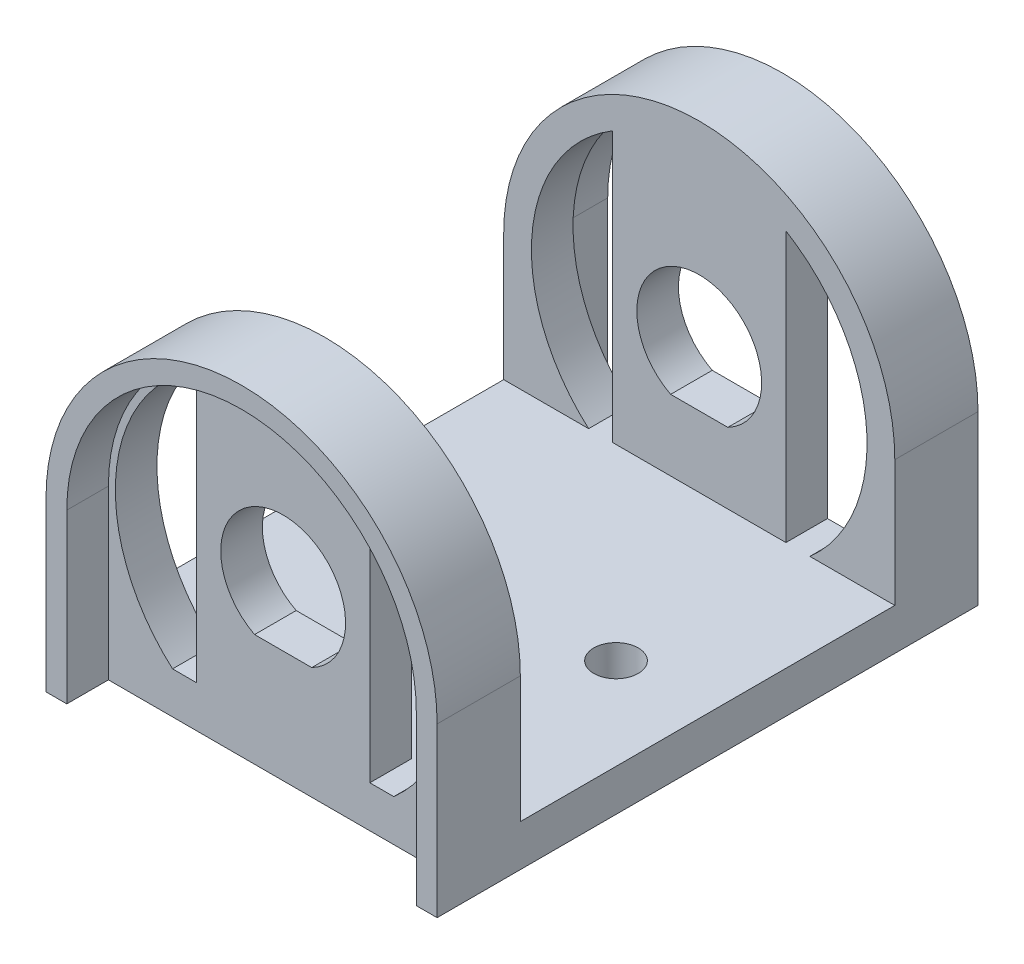
from build123d import *

# Parameters (mm, degrees)
BOSS_EXTRUDE2_DEPTH     = 19.5
SKETCH4_W               = 27
SKETCH4_H               = 23.2
CUT_EXTRUDE2_DEPTH      = 15.1
CUT_EXTRUDE2_DEPTH_BACK = 15.1
CUT_EXTRUDE4_DEPTH      = 3
SKETCH5_R               = 1.6
CUT_EXTRUDE5_DEPTH      = 14.1
CUT_EXTRUDE5_DEPTH_BACK = 14.1


with BuildPart() as part:
    # Sketch2 → Boss-Extrude2 (new body, symmetric)
    with BuildSketch(Plane.XY):
        with BuildLine():
            Line((-14.1, -13.1), (14.1, -13.1))
            Line((14.1, -13.1), (14.1, -1))
            ThreePointArc((14.1, -1), (0, 13.1), (-14.1, -1))
            Line((-14.1, -1), (-14.1, -13.1))
        make_face()
        with BuildLine():
            Line((6.25, 9.360863864), (6.25, -10.1))
            Line((6.25, -10.1), (7.974960815, -10.1))
            ThreePointArc((7.974960815, -10.1), (12.052745875, 0.06832433), (6.25, 9.360863864))
        make_face(mode=Mode.SUBTRACT)
        with BuildLine():
            Line((-6.25, 9.360863864), (-6.25, -10.1))
            Line((-6.25, -10.1), (-7.974960815, -10.1))
            ThreePointArc((-7.974960815, -10.1), (-12.052745875, 0.06832433), (-6.25, 9.360863864))
        make_face(mode=Mode.SUBTRACT)
        with BuildLine():
            Line((2.061552813, -5), (-2.061552813, -5))
            ThreePointArc((-2.061552813, -5), (0, 3.5), (2.061552813, -5))
        make_face(mode=Mode.SUBTRACT)
    extrude(amount=BOSS_EXTRUDE2_DEPTH, both=True)

    # Sketch4 → Cut-Extrude2 (cut, two sides)
    with BuildSketch(Plane(origin=(0, 0, 0), x_dir=(0, 0, -1), z_dir=(1, 0, 0))) as cut_extrude2_sk:
        with Locations((0, 1.5)):
            Rectangle(SKETCH4_W, SKETCH4_H)
    extrude(amount=CUT_EXTRUDE2_DEPTH, mode=Mode.SUBTRACT)
    extrude(cut_extrude2_sk.sketch, amount=-CUT_EXTRUDE2_DEPTH_BACK, mode=Mode.SUBTRACT)

    # Sketch3 → Cut-Extrude4 (cut)
    with BuildSketch(Plane.XY.offset(19.5)):
        with BuildLine():
            Line((-12.6, -1), (-12.6, -13.1))
            Line((-12.6, -13.1), (12.6, -13.1))
            Line((12.6, -13.1), (12.6, -1))
            ThreePointArc((12.6, -1), (0, 11.6), (-12.6, -1))
        make_face()
    cut_extrude4 = extrude(amount=-CUT_EXTRUDE4_DEPTH, mode=Mode.SUBTRACT)

    # Sketch5 → Cut-Extrude5 (cut, two sides)
    with BuildSketch(Plane(origin=(0, 0, 0), x_dir=(1, 0, 0), z_dir=(0, 1, 0))) as cut_extrude5_sk:
        with Locations((7.5, 0)):
            Circle(SKETCH5_R)
        with Locations((-7.5, 0)):
            Circle(SKETCH5_R)
    extrude(amount=CUT_EXTRUDE5_DEPTH, mode=Mode.SUBTRACT)
    extrude(cut_extrude5_sk.sketch, amount=-CUT_EXTRUDE5_DEPTH_BACK, mode=Mode.SUBTRACT)

    # Mirror2: Cut-Extrude4 across plane
    add(cut_extrude4.mirror(Plane.XY), mode=Mode.SUBTRACT)


solid = part.part
